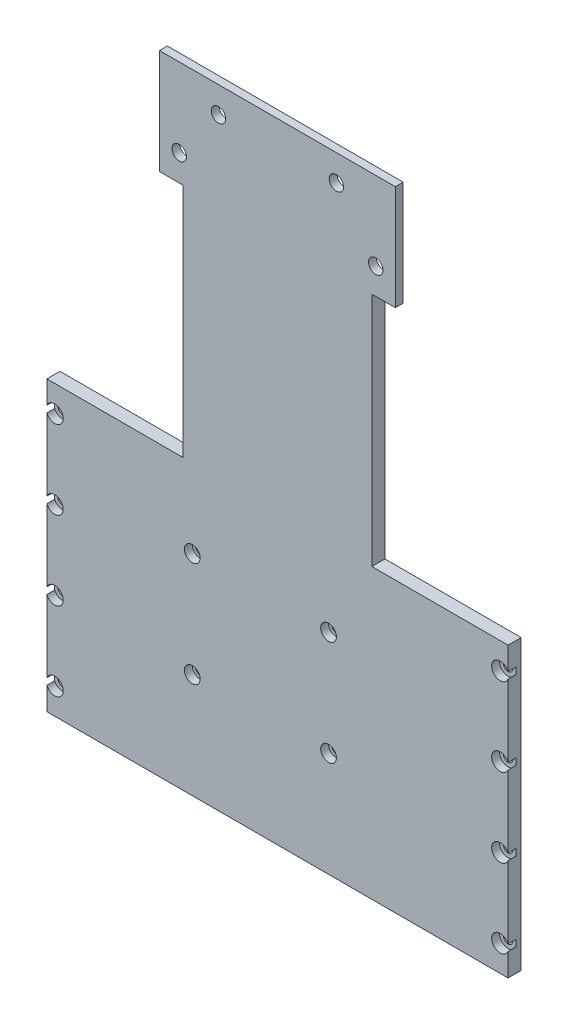
from build123d import *

# Parameters (mm, degrees)
EXTRUDE_1_DEPTH     = 3
SKETCH_2_W          = 72
SKETCH_2_H          = 200
EXTRUDE_2_DEPTH     = 2
SKETCH_4_R          = 2.75
CUT_EXTRUDE_1_DEPTH = 4
SKETCH_7_W          = 52
SKETCH_7_H          = 110
EXTRUDE_3_DEPTH     = 5
SKETCH_8_R          = 1.75
CUT_EXTRUDE_2_DEPTH = 6
SKETCH_9_R          = 3.25
CUT_EXTRUDE_3_DEPTH = 3
SKETCH_10_R         = 1.75
CUT_EXTRUDE_4_DEPTH = 6
SKETCH_11_R         = 3
CUT_EXTRUDE_5_DEPTH = 3


with BuildPart() as part:
    # Sketch 1 → Extrude 1 (new body)
    with BuildSketch(Plane.XY):
        Polygon((-45, -20), (-36, -20), (-36, -220), (36, -220), (36, -20), (45, -20), (45, 20), (-45, 20), align=None)
    extrude_1 = extrude(amount=EXTRUDE_1_DEPTH)

    # Sketch 2 → Extrude 2 (add)
    with BuildSketch(Plane(origin=(0, 0, 0), x_dir=(-1, 0, 0), z_dir=(0, 0, -1))):
        with Locations((0, -120)):
            Rectangle(SKETCH_2_W, SKETCH_2_H)
    extrude(amount=EXTRUDE_2_DEPTH)

    # Sketch 4 → Cut-Extrude 1 (cut, through all)
    with BuildSketch(Plane(origin=(0, 0, 0), x_dir=(-1, 0, 0), z_dir=(0, 0, -1))):
        with Locations((-22.5, 10)):
            Circle(SKETCH_4_R)
        with Locations((22.5, 10)):
            Circle(SKETCH_4_R)
        with Locations((37.5, -10)):
            Circle(SKETCH_4_R)
        with Locations((-37.5, -10)):
            Circle(SKETCH_4_R)
    cut_extrude_1 = extrude(amount=-CUT_EXTRUDE_1_DEPTH, mode=Mode.SUBTRACT)

    # Sketch 7 → Extrude 3 (add)
    with BuildSketch(Plane.XY.offset(3)):
        with Locations((62, -165)):
            Rectangle(SKETCH_7_W, SKETCH_7_H)
    extrude_3 = extrude(amount=-EXTRUDE_3_DEPTH)

    # Sketch 8 → Cut-Extrude 2 (cut, through all)
    with BuildSketch(Plane.XY.offset(3)):
        with Locations((85, -180)):
            Circle(SKETCH_8_R)
        with Locations((85, -210)):
            Circle(SKETCH_8_R)
        with Locations((85, -150)):
            Circle(SKETCH_8_R)
        with Locations((85, -120)):
            Circle(SKETCH_8_R)
    cut_extrude_2 = extrude(amount=-CUT_EXTRUDE_2_DEPTH, mode=Mode.SUBTRACT)

    # Sketch 9 → Cut-Extrude 3 (cut)
    with BuildSketch(Plane.XY.offset(3)):
        with Locations((85, -180)):
            Circle(SKETCH_9_R)
        with Locations((85, -210)):
            Circle(SKETCH_9_R)
        with Locations((85, -150)):
            Circle(SKETCH_9_R)
        with Locations((85, -120)):
            Circle(SKETCH_9_R)
    cut_extrude_3 = extrude(amount=-CUT_EXTRUDE_3_DEPTH, mode=Mode.SUBTRACT)

    # Mirror 1: Extrude 1, Cut-Extrude 1, Extrude 3, Cut-Extrude 2, Cut-Extrude 3 across plane
    add(extrude_1.mirror(Plane(origin=(0, 0, 0), x_dir=(0, 0, 1), z_dir=(1, 0, 0))))
    add(cut_extrude_1.mirror(Plane(origin=(0, 0, 0), x_dir=(0, 0, 1), z_dir=(1, 0, 0))), mode=Mode.SUBTRACT)
    add(extrude_3.mirror(Plane(origin=(0, 0, 0), x_dir=(0, 0, 1), z_dir=(1, 0, 0))))
    add(cut_extrude_2.mirror(Plane(origin=(0, 0, 0), x_dir=(0, 0, 1), z_dir=(1, 0, 0))), mode=Mode.SUBTRACT)
    add(cut_extrude_3.mirror(Plane(origin=(0, 0, 0), x_dir=(0, 0, 1), z_dir=(1, 0, 0))), mode=Mode.SUBTRACT)

    # Sketch 10 → Cut-Extrude 4 (cut, through all)
    with BuildSketch(Plane.XY.offset(3)):
        with Locations((19.5, -140)):
            Circle(SKETCH_10_R)
        with Locations((19.5, -180)):
            Circle(SKETCH_10_R)
        with Locations((-32.5, -180)):
            Circle(SKETCH_10_R)
        with Locations((-32.5, -140)):
            Circle(SKETCH_10_R)
    extrude(amount=-CUT_EXTRUDE_4_DEPTH, mode=Mode.SUBTRACT)

    # Sketch 11 → Cut-Extrude 5 (cut)
    with BuildSketch(Plane.XY.offset(3)):
        with Locations((-32.5, -140)):
            Circle(SKETCH_11_R)
        with Locations((19.5, -140)):
            Circle(SKETCH_11_R)
        with Locations((19.5, -180)):
            Circle(SKETCH_11_R)
        with Locations((-32.5, -180)):
            Circle(SKETCH_11_R)
    extrude(amount=-CUT_EXTRUDE_5_DEPTH, mode=Mode.SUBTRACT)


solid = part.part
